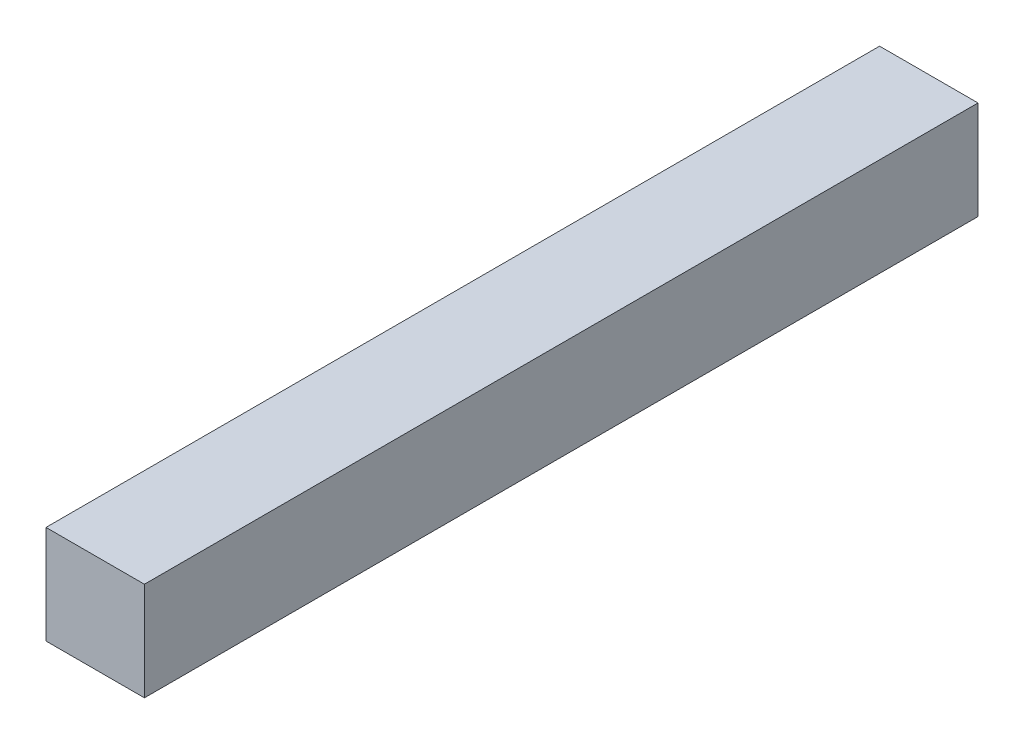
from build123d import *

# Parameters (mm, degrees)
SKETCH2_W           = 3
SKETCH2_H           = 3
BOSS_EXTRUDE1_DEPTH = 25.41


with BuildPart() as part:
    # Sketch2 → Boss-Extrude1 (new body)
    with BuildSketch(Plane.XY):
        with Locations((1.5, 1.5)):
            Rectangle(SKETCH2_W, SKETCH2_H)
    extrude(amount=BOSS_EXTRUDE1_DEPTH)


solid = part.part
